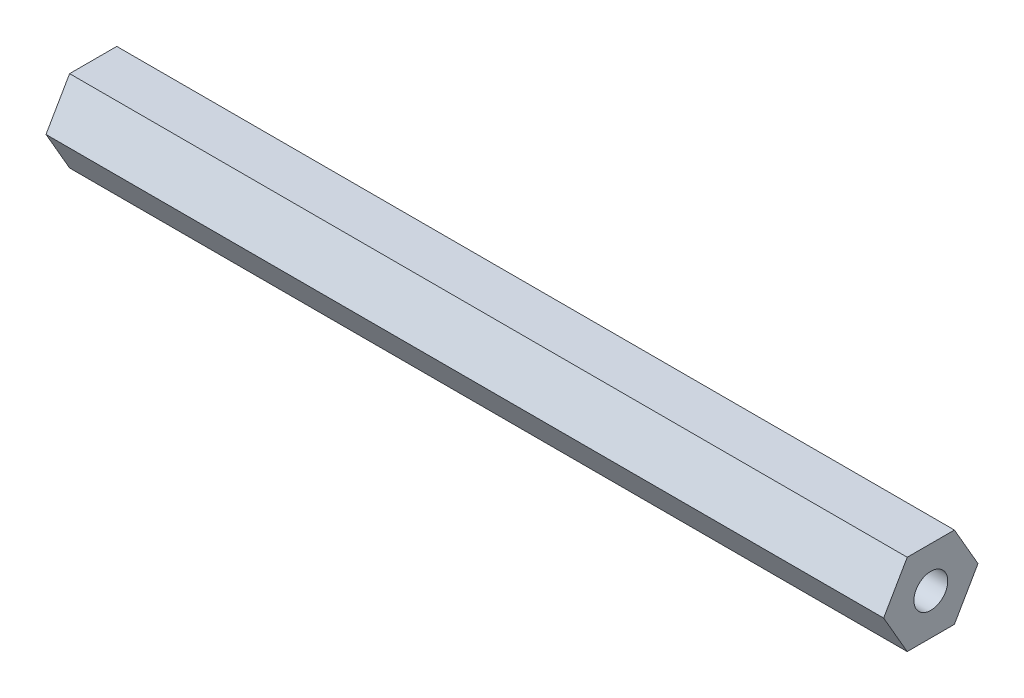
from build123d import *

# Parameters (mm, degrees)
SKETCH1_R           = 2.6289
BOSS_EXTRUDE1_DEPTH = 130.175


with BuildPart() as part:
    # Sketch1 → Boss-Extrude1 (new body)
    with BuildSketch(Plane(origin=(0, 0, 0), x_dir=(0, 0, -1), z_dir=(1, 0, 0))):
        Polygon((3.666174209, 6.35), (-3.666174209, 6.35), (-7.332348419, 0), (-3.666174209, -6.35), (3.666174209, -6.35), (7.332348419, 0), align=None)
        Circle(SKETCH1_R, mode=Mode.SUBTRACT)
    extrude(amount=BOSS_EXTRUDE1_DEPTH)


solid = part.part
